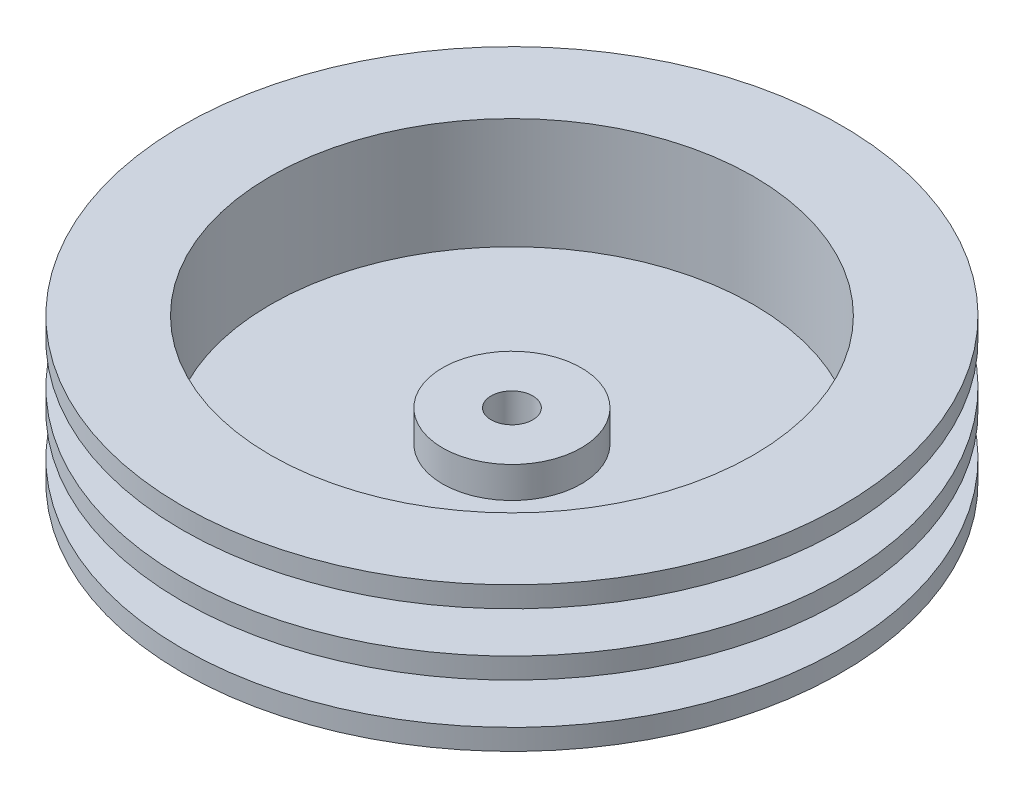
from build123d import *

# Parameters (mm, degrees)
SKETCH2_R          = 1.5
CUT_EXTRUDE1_DEPTH = 5.65


with BuildPart() as part:
    # Sketch1 → Revolve1 (revolve)
    with BuildSketch(Plane.XY):
        Polygon((0, 0), (23.75, 0), (23.75, 1.5), (18.9, 1.5), (18.9, 4.45), (23.75, 4.45), (23.75, 5.95), (18.9, 5.95), (18.9, 8.9), (23.75, 8.9), (23.75, 10.4), (17.4, 10.4), (17.4, 2.4), (5, 2.4), (5, 4.65), (0, 4.65), align=None)
    revolve(axis=Axis((0, 4.65, 0), (0, -1, 0)))

    # Sketch2 → Cut-Extrude1 (cut, through all)
    with BuildSketch(Plane(origin=(0, 4.65, 0), x_dir=(1, 0, 0), z_dir=(0, 1, 0))):
        Circle(SKETCH2_R)
    extrude(amount=-CUT_EXTRUDE1_DEPTH, mode=Mode.SUBTRACT)


solid = part.part
